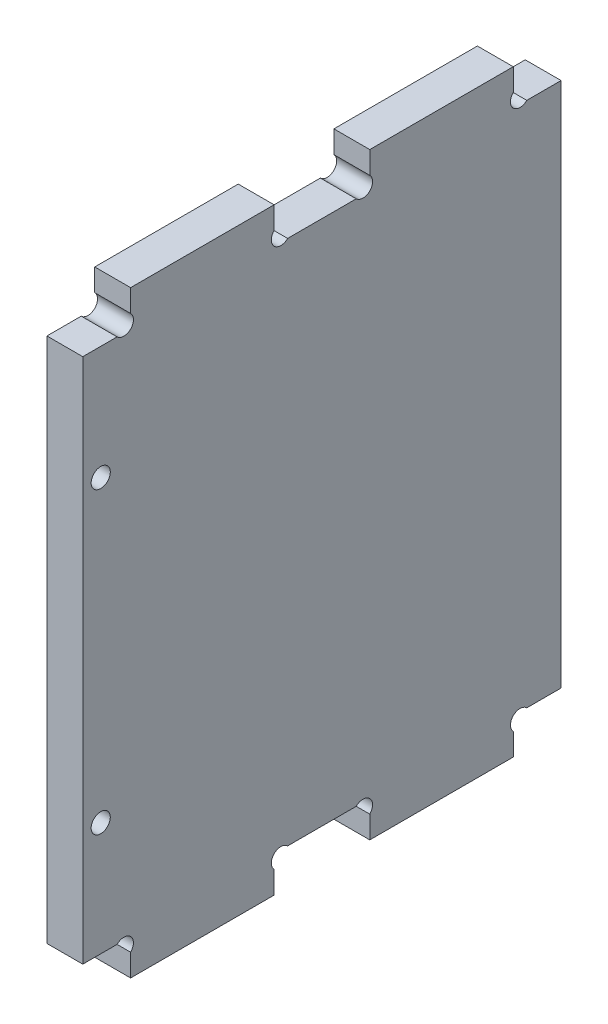
from build123d import *

# Parameters (mm, degrees)
ESQUISSE1_R      = 1.6
EXTRUSION1_DEPTH = 6


with BuildPart() as part:
    # Esquisse1 → Extrusion1 (new body)
    with BuildSketch(Plane(origin=(0, 0, 0), x_dir=(0, 0, -1), z_dir=(1, 0, 0))):
        with BuildLine():
            Line((0, 94), (5.7372583, 94))
            ThreePointArc((5.7372583, 94), (8, 94), (8, 96.2627417))
            Line((8, 96.2627417), (8, 100))
            Line((8, 100), (32, 100))
            Line((32, 100), (32, 96.2627417))
            ThreePointArc((32, 96.2627417), (32, 94), (34.2627417, 94))
            Line((34.2627417, 94), (45.7372583, 94))
            ThreePointArc((45.7372583, 94), (48, 94), (48, 96.2627417))
            Line((48, 96.2627417), (48, 100))
            Line((48, 100), (72, 100))
            Line((72, 100), (72, 96.2627417))
            ThreePointArc((72, 96.2627417), (72, 94), (74.2627417, 94))
            Line((74.2627417, 94), (80, 94))
            Line((80, 94), (80, 6))
            Line((80, 6), (74.2627417, 6))
            ThreePointArc((74.2627417, 6), (72, 6), (72, 3.7372583))
            Line((72, 3.7372583), (72, 0))
            Line((72, 0), (48, 0))
            Line((48, 0), (48, 3.7372583))
            ThreePointArc((48, 3.7372583), (48, 6), (45.7372583, 6))
            Line((45.7372583, 6), (34.2627417, 6))
            ThreePointArc((34.2627417, 6), (32, 6), (32, 3.7372583))
            Line((32, 3.7372583), (32, 0))
            Line((32, 0), (8, 0))
            Line((8, 0), (8, 3.7372583))
            ThreePointArc((8, 3.7372583), (8, 6), (5.7372583, 6))
            Line((5.7372583, 6), (0, 6))
            Line((0, 6), (0, 94))
        make_face()
        with Locations((3, 25)):
            Circle(ESQUISSE1_R, mode=Mode.SUBTRACT)
        with Locations(Location((3, 75, 0), (0, 0, 180))):  # turned: the seam where the file's is
            Circle(ESQUISSE1_R, mode=Mode.SUBTRACT)
    extrude(amount=EXTRUSION1_DEPTH)


solid = part.part
